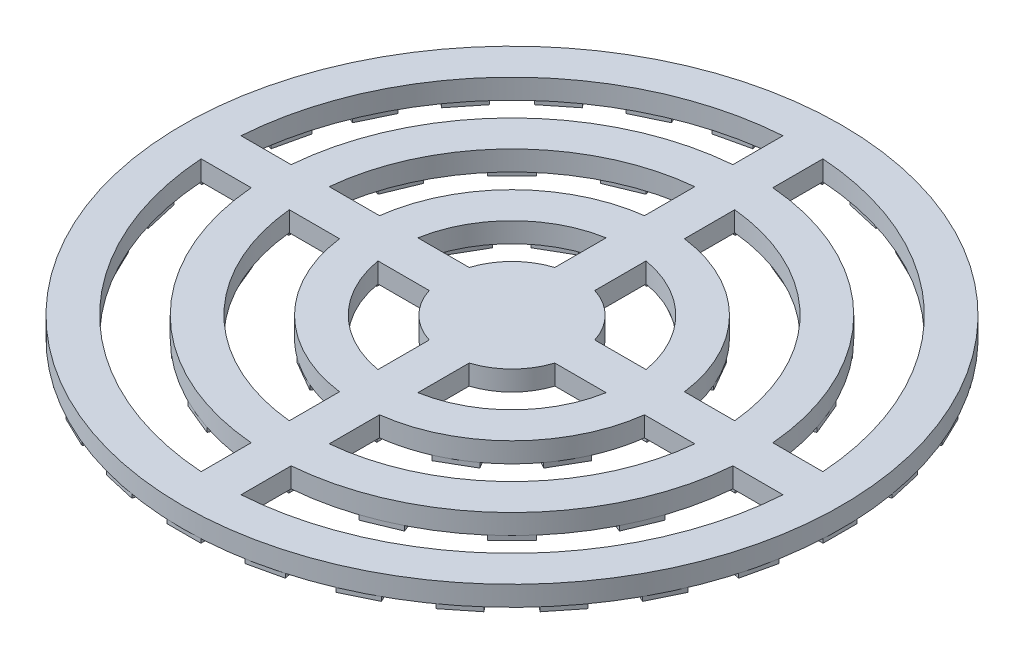
from build123d import *

# Parameters (mm, degrees)
SKETCH1_R           = 33
BOSS_EXTRUDE1_DEPTH = 2
CUT_EXTRUDE1_DEPTH  = 2
SKETCH3_W           = 3.4
SKETCH3_H           = 3.5
SKETCH3_W_2         = 3.5
SKETCH3_H_2         = 3.4
BOSS_EXTRUDE2_DEPTH = 0.5


with BuildPart() as part:
    # Sketch1 → Boss-Extrude1 (new body)
    with BuildSketch(Plane(origin=(0, 0, 0), x_dir=(1, 0, 0), z_dir=(0, 1, 0))):
        Circle(SKETCH1_R)
    extrude(amount=BOSS_EXTRUDE1_DEPTH)

    # Sketch2 → Cut-Extrude1 (cut)
    with BuildSketch(Plane(origin=(0, 2, 0), x_dir=(1, 0, 0), z_dir=(0, 1, 0))):
        with BuildLine():
            Line((-24.117213769, -2), (-29.13142633, -2))
            ThreePointArc((-29.13142633, -2), (-20.647518011, -20.647518011), (-2, -29.13142633))
            Line((-2, -29.13142633), (-2, -24.117213769))
            ThreePointArc((-2, -24.117213769), (-17.111984105, -17.111984105), (-24.117213769, -2))
        make_face()
        with BuildLine():
            ThreePointArc((-2, 29.13142633), (-20.647518011, 20.647518011), (-29.13142633, 2))
            Line((-29.13142633, 2), (-24.117213769, 2))
            ThreePointArc((-24.117213769, 2), (-17.111984105, 17.111984105), (-2, 24.117213769))
            Line((-2, 24.117213769), (-2, 29.13142633))
        make_face()
        with BuildLine():
            ThreePointArc((29.13142633, 2), (20.647518011, 20.647518011), (2, 29.13142633))
            Line((2, 29.13142633), (2, 24.117213769))
            ThreePointArc((2, 24.117213769), (17.111984105, 17.111984105), (24.117213769, 2))
            Line((24.117213769, 2), (29.13142633, 2))
        make_face()
        with BuildLine():
            Line((2, -24.117213769), (2, -29.13142633))
            ThreePointArc((2, -29.13142633), (20.647518011, -20.647518011), (29.13142633, -2))
            Line((29.13142633, -2), (24.117213769, -2))
            ThreePointArc((24.117213769, -2), (17.111984105, -17.111984105), (2, -24.117213769))
        make_face()
        with BuildLine():
            Line((2, -15.269577597), (2, -20.301724065))
            ThreePointArc((2, -20.301724065), (14.424978336, -14.424978336), (20.301724065, -2))
            Line((20.301724065, -2), (15.269577597, -2))
            ThreePointArc((15.269577597, -2), (10.88944443, -10.88944443), (2, -15.269577597))
        make_face()
        with BuildLine():
            ThreePointArc((20.301724065, 2), (14.424978336, 14.424978336), (2, 20.301724065))
            Line((2, 20.301724065), (2, 15.269577597))
            ThreePointArc((2, 15.269577597), (10.88944443, 10.88944443), (15.269577597, 2))
            Line((15.269577597, 2), (20.301724065, 2))
        make_face()
        with BuildLine():
            ThreePointArc((-2, 20.301724065), (-14.424978336, 14.424978336), (-20.301724065, 2))
            Line((-20.301724065, 2), (-15.269577597, 2))
            ThreePointArc((-15.269577597, 2), (-10.88944443, 10.88944443), (-2, 15.269577597))
            Line((-2, 15.269577597), (-2, 20.301724065))
        make_face()
        with BuildLine():
            Line((-15.269577597, -2), (-20.301724065, -2))
            ThreePointArc((-20.301724065, -2), (-14.424978336, -14.424978336), (-2, -20.301724065))
            Line((-2, -20.301724065), (-2, -15.269577597))
            ThreePointArc((-2, -15.269577597), (-10.88944443, -10.88944443), (-15.269577597, -2))
        make_face()
        with BuildLine():
            Line((-6.289674077, -2), (-11.426285486, -2))
            ThreePointArc((-11.426285486, -2), (-8.202438662, -8.202438662), (-2, -11.426285486))
            Line((-2, -11.426285486), (-2, -6.289674077))
            ThreePointArc((-2, -6.289674077), (-4.666904756, -4.666904756), (-6.289674077, -2))
        make_face()
        with BuildLine():
            ThreePointArc((-2, 11.426285486), (-8.202438662, 8.202438662), (-11.426285486, 2))
            Line((-11.426285486, 2), (-6.289674077, 2))
            ThreePointArc((-6.289674077, 2), (-4.666904756, 4.666904756), (-2, 6.289674077))
            Line((-2, 6.289674077), (-2, 11.426285486))
        make_face()
        with BuildLine():
            ThreePointArc((11.426285486, 2), (8.202438662, 8.202438662), (2, 11.426285486))
            Line((2, 11.426285486), (2, 6.289674077))
            ThreePointArc((2, 6.289674077), (4.666904756, 4.666904756), (6.289674077, 2))
            Line((6.289674077, 2), (11.426285486, 2))
        make_face()
        with BuildLine():
            Line((2, -6.289674077), (2, -11.426285486))
            ThreePointArc((2, -11.426285486), (8.202438662, -8.202438662), (11.426285486, -2))
            Line((11.426285486, -2), (6.289674077, -2))
            ThreePointArc((6.289674077, -2), (4.666904756, -4.666904756), (2, -6.289674077))
        make_face()
    extrude(amount=-CUT_EXTRUDE1_DEPTH, mode=Mode.SUBTRACT)

    # Sketch3 → Boss-Extrude2 (add)
    with BuildSketch(Plane(origin=(0, 0, 0), x_dir=(-1, 0, 0), z_dir=(0, -1, 0))):
        with Locations((0, 31.1)):
            Rectangle(SKETCH3_W, SKETCH3_H)
        with Locations((0, 22.35)):
            Rectangle(SKETCH3_W_2, SKETCH3_H)
        with Locations((0, 13.5)):
            Rectangle(SKETCH3_W_2, SKETCH3_H)
        Polygon((4.873611961, 28.99241981), (8.188366862, 28.235848635), (8.967190131, 31.648096327), (5.65243523, 32.404667503), align=None)
        Polygon((11.202840668, 27.181038629), (14.266134819, 25.705833916), (15.784727905, 28.859224954), (12.721433755, 30.334429667), align=None)
        Polygon((16.970312164, 24.006686674), (19.628539205, 21.886821347), (21.810753511, 24.623231536), (19.152526471, 26.743096862), align=None)
        Polygon((21.886821347, 19.628539205), (24.006686674, 16.970312164), (26.743096862, 19.152526471), (24.623231536, 21.810753511), align=None)
        Polygon((25.705833916, 14.266134819), (27.181038629, 11.202840668), (30.334429667, 12.721433755), (28.859224954, 15.784727905), align=None)
        Polygon((28.235848635, 8.188366862), (28.99241981, 4.873611961), (32.404667503, 5.65243523), (31.648096327, 8.967190131), align=None)
        with Locations((31.1, 0)):
            Rectangle(SKETCH3_W_2, SKETCH3_H_2)
        Polygon((28.99241981, -4.873611961), (28.235848635, -8.188366862), (31.648096327, -8.967190131), (32.404667503, -5.65243523), align=None)
        Polygon((27.181038629, -11.202840668), (25.705833916, -14.266134819), (28.859224954, -15.784727905), (30.334429667, -12.721433755), align=None)
        Polygon((24.006686674, -16.970312164), (21.886821347, -19.628539205), (24.623231536, -21.810753511), (26.743096862, -19.152526471), align=None)
        Polygon((19.628539205, -21.886821347), (16.970312164, -24.006686674), (19.152526471, -26.743096862), (21.810753511, -24.623231536), align=None)
        Polygon((14.266134819, -25.705833916), (11.202840668, -27.181038629), (12.721433755, -30.334429667), (15.784727905, -28.859224954), align=None)
        Polygon((8.188366862, -28.235848635), (4.873611961, -28.99241981), (5.65243523, -32.404667503), (8.967190131, -31.648096327), align=None)
        with Locations((0, -31.1)):
            Rectangle(SKETCH3_W, SKETCH3_H)
        Polygon((-4.873611961, -28.99241981), (-8.188366862, -28.235848635), (-8.967190131, -31.648096327), (-5.65243523, -32.404667503), align=None)
        Polygon((-11.202840668, -27.181038629), (-14.266134819, -25.705833916), (-15.784727905, -28.859224954), (-12.721433755, -30.334429667), align=None)
        Polygon((-16.970312164, -24.006686674), (-19.628539205, -21.886821347), (-21.810753511, -24.623231536), (-19.152526471, -26.743096862), align=None)
        Polygon((-21.886821347, -19.628539205), (-24.006686674, -16.970312164), (-26.743096862, -19.152526471), (-24.623231536, -21.810753511), align=None)
        Polygon((-25.705833916, -14.266134819), (-27.181038629, -11.202840668), (-30.334429667, -12.721433755), (-28.859224954, -15.784727905), align=None)
        Polygon((-28.235848635, -8.188366862), (-28.99241981, -4.873611961), (-32.404667503, -5.65243523), (-31.648096327, -8.967190131), align=None)
        with Locations((-31.1, 0)):
            Rectangle(SKETCH3_W_2, SKETCH3_H_2)
        Polygon((-28.99241981, 4.873611961), (-28.235848635, 8.188366862), (-31.648096327, 8.967190131), (-32.404667503, 5.65243523), align=None)
        Polygon((-27.181038629, 11.202840668), (-25.705833916, 14.266134819), (-28.859224954, 15.784727905), (-30.334429667, 12.721433755), align=None)
        Polygon((-24.006686674, 16.970312164), (-21.886821347, 19.628539205), (-24.623231536, 21.810753511), (-26.743096862, 19.152526471), align=None)
        Polygon((-19.628539205, 21.886821347), (-16.970312164, 24.006686674), (-19.152526471, 26.743096862), (-21.810753511, 24.623231536), align=None)
        Polygon((-14.266134819, 25.705833916), (-11.202840668, 27.181038629), (-12.721433755, 30.334429667), (-15.784727905, 28.859224954), align=None)
        Polygon((-8.188366862, 28.235848635), (-4.873611961, 28.99241981), (-5.65243523, 32.404667503), (-8.967190131, 31.648096327), align=None)
        Polygon((7.605881538, 22.93519274), (10.839459902, 21.595800727), (9.500067889, 18.362222363), (6.266489525, 19.701614376), align=None)
        Polygon((15.80383656, 18.278710294), (18.278710294, 15.80383656), (15.80383656, 13.328962825), (13.328962825, 15.80383656), align=None)
        Polygon((21.595800727, 10.839459902), (22.93519274, 7.605881538), (19.701614376, 6.266489525), (18.362222363, 9.500067889), align=None)
        with Locations((22.35, 0)):
            Rectangle(SKETCH3_W_2, SKETCH3_H)
        Polygon((22.93519274, -7.605881538), (21.595800727, -10.839459902), (18.362222363, -9.500067889), (19.701614376, -6.266489525), align=None)
        Polygon((18.278710294, -15.80383656), (15.80383656, -18.278710294), (13.328962825, -15.80383656), (15.80383656, -13.328962825), align=None)
        Polygon((10.839459902, -21.595800727), (7.605881538, -22.93519274), (6.266489525, -19.701614376), (9.500067889, -18.362222363), align=None)
        with Locations((0, -22.35)):
            Rectangle(SKETCH3_W_2, SKETCH3_H)
        Polygon((-7.605881538, -22.93519274), (-10.839459902, -21.595800727), (-9.500067889, -18.362222363), (-6.266489525, -19.701614376), align=None)
        Polygon((-15.80383656, -18.278710294), (-18.278710294, -15.80383656), (-15.80383656, -13.328962825), (-13.328962825, -15.80383656), align=None)
        Polygon((-21.595800727, -10.839459902), (-22.93519274, -7.605881538), (-19.701614376, -6.266489525), (-18.362222363, -9.500067889), align=None)
        with Locations((-22.35, 0)):
            Rectangle(SKETCH3_W_2, SKETCH3_H)
        Polygon((-22.93519274, 7.605881538), (-21.595800727, 10.839459902), (-18.362222363, 9.500067889), (-19.701614376, 6.266489525), align=None)
        Polygon((-18.278710294, 15.80383656), (-15.80383656, 18.278710294), (-13.328962825, 15.80383656), (-15.80383656, 13.328962825), align=None)
        Polygon((-10.839459902, 21.595800727), (-7.605881538, 22.93519274), (-6.266489525, 19.701614376), (-9.500067889, 18.362222363), align=None)
        Polygon((7.400073359, 9.298245233), (9.150073359, 12.329334146), (6.118984446, 14.079334146), (4.368984446, 11.048245233), align=None)
        Polygon((11.067303038, 4.349926641), (14.098391952, 6.099926641), (12.348391952, 9.131015554), (9.317303038, 7.381015554), align=None)
        with Locations((13.519057806, -0.019057806)):
            Rectangle(SKETCH3_W_2, SKETCH3_H)
        Polygon((9.317303038, -7.419131165), (12.348391952, -9.169131165), (14.098391952, -6.138042252), (11.067303038, -4.388042252), align=None)
        Polygon((4.368984446, -11.086360844), (6.118984446, -14.117449757), (9.150073359, -12.367449757), (7.400073359, -9.336360844), align=None)
        with Locations((0, -13.538115611)):
            Rectangle(SKETCH3_W_2, SKETCH3_H)
        Polygon((-7.400073359, -9.336360844), (-9.150073359, -12.367449757), (-6.118984446, -14.117449757), (-4.368984446, -11.086360844), align=None)
        Polygon((-11.067303038, -4.388042252), (-14.098391952, -6.138042252), (-12.348391952, -9.169131165), (-9.317303038, -7.419131165), align=None)
        with Locations((-13.519057806, -0.019057806)):
            Rectangle(SKETCH3_W_2, SKETCH3_H)
        Polygon((-9.317303038, 7.381015554), (-12.348391952, 9.131015554), (-14.098391952, 6.099926641), (-11.067303038, 4.349926641), align=None)
        Polygon((-4.368984446, 11.048245233), (-6.118984446, 14.079334146), (-9.150073359, 12.329334146), (-7.400073359, 9.298245233), align=None)
        Polygon((-5.126524164, 2.651650429), (-2.651650429, 0.176776695), (-0.176776695, 2.651650429), (-2.651650429, 5.126524164), align=None)
        Polygon((5.126524164, 2.651650429), (2.651650429, 5.126524164), (0.176776695, 2.651650429), (2.651650429, 0.176776695), align=None)
        Polygon((2.651650429, -5.126524164), (5.126524164, -2.651650429), (2.651650429, -0.176776695), (0.176776695, -2.651650429), align=None)
        Polygon((-5.126524164, -2.651650429), (-2.651650429, -5.126524164), (-0.176776695, -2.651650429), (-2.651650429, -0.176776695), align=None)
    extrude(amount=BOSS_EXTRUDE2_DEPTH)


solid = part.part
